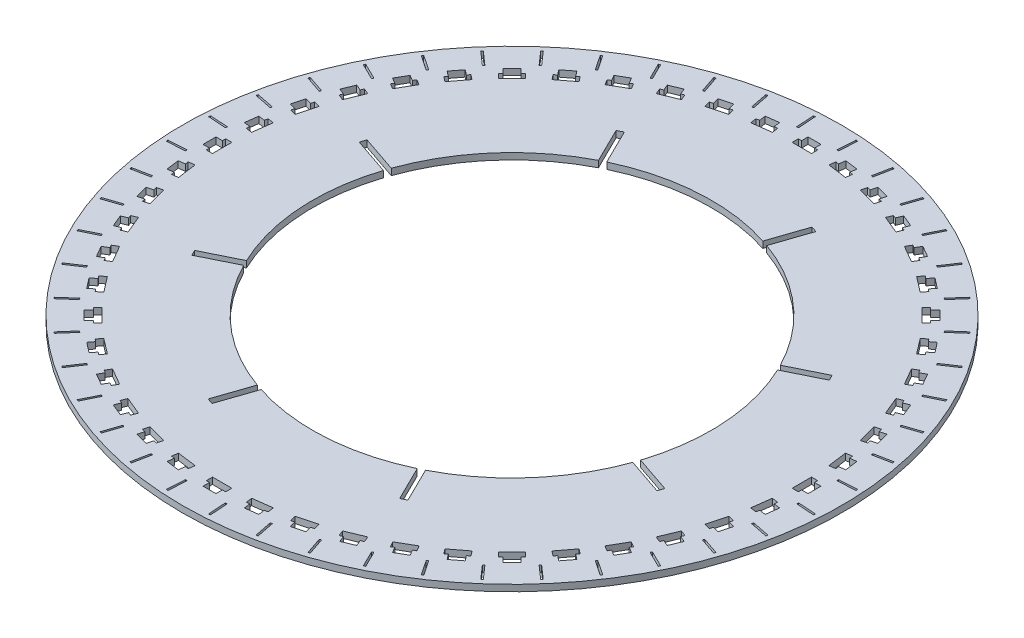
from build123d import *

# Parameters (mm, degrees)
SKETCH_1_R               = 254.62
SKETCH_1_R_2             = 154.62
EXTRUDE_1_DEPTH          = 5
SKETCH_2_W               = 10
SKETCH_2_H               = 5
CUT_EXTRUDE_1_DEPTH      = 6
PATTERN_CIRCULAR_1_COUNT = 48
CUT_EXTRUDE_2_DEPTH      = 5
PATTERN_CIRCULAR_2_COUNT = 48
SKETCH_4_R               = 255.62
SKETCH_4_R_2             = 254.62
EXTRUDE_2_DEPTH          = 5
CUT_EXTRUDE_3_DEPTH      = 5
PATTERN_CIRCULAR_3_COUNT = 8


with BuildPart() as part:
    # 草图1 → 凸台-拉伸1 (new body)
    with BuildSketch(Plane(origin=(0, 0, 0), x_dir=(1, 0, 0), z_dir=(0, 1, 0))):
        Circle(SKETCH_1_R)
        Circle(SKETCH_1_R_2, mode=Mode.SUBTRACT)
    extrude(amount=EXTRUDE_1_DEPTH)

    # 草图2 → 切除-拉伸1 (cut, through all)
    with BuildSketch(Plane(origin=(0, 5, 0), x_dir=(1, 0, 0), z_dir=(0, 1, 0))):
        Polygon((-7.5, -229.62), (-5, -229.62), (5, -229.62), (7.5, -229.62), (7.5, -224.82), (-7.5, -224.82), align=None)
        with Locations((0, -232.12)):
            Rectangle(SKETCH_2_W, SKETCH_2_H)
    cut_extrude_1 = extrude(amount=-CUT_EXTRUDE_1_DEPTH, mode=Mode.SUBTRACT)

    # 阵列(圆周)1: 切除-拉伸1 ×48 about axis
    pattern_circular_1_axis = Axis((0, 0, 0), (0, 1, 0))
    for i in range(1, PATTERN_CIRCULAR_1_COUNT):
        add(cut_extrude_1.rotate(pattern_circular_1_axis, i * 360 / PATTERN_CIRCULAR_1_COUNT), mode=Mode.SUBTRACT)

    # 草图3 → 切除-拉伸2 (cut)
    with BuildSketch(Plane(origin=(0, 5, 0), x_dir=(1, 0, 0), z_dir=(0, 1, 0))):
        Polygon((15.758234131, -251.127044456), (14.842590321, -237.15701953), (16.239592814, -237.065455149), (17.155236623, -251.035480075), align=None)
    cut_extrude_2 = extrude(amount=-CUT_EXTRUDE_2_DEPTH, mode=Mode.SUBTRACT)

    # 阵列(圆周)2: 切除-拉伸2 ×48 about axis
    pattern_circular_2_axis = Axis((0, 0, 0), (0, 1, 0))
    for i in range(1, PATTERN_CIRCULAR_2_COUNT):
        add(cut_extrude_2.rotate(pattern_circular_2_axis, i * 360 / PATTERN_CIRCULAR_2_COUNT), mode=Mode.SUBTRACT)

    # 草图4 → 凸台-拉伸2 (add)
    with BuildSketch(Plane(origin=(0, 5, 0), x_dir=(1, 0, 0), z_dir=(0, 1, 0))):
        Circle(SKETCH_4_R)
        Circle(SKETCH_4_R_2, mode=Mode.SUBTRACT)
    extrude(amount=-EXTRUDE_2_DEPTH)

    # 草图6 → 切除-拉伸3 (cut)
    with BuildSketch(Plane(origin=(0, 5, 0), x_dir=(1, 0, 0), z_dir=(0, 1, 0))):
        Polygon((112.829773906, 52.965521995), (166.642138398, 79.502843409), (164.519152685, 83.807832568), (110.706788193, 57.270511155), align=None)
    cut_extrude_3 = extrude(amount=-CUT_EXTRUDE_3_DEPTH, mode=Mode.SUBTRACT)

    # 阵列(圆周)3: 切除-拉伸3 ×8 about axis
    pattern_circular_3_axis = Axis((0, 0, 0), (0, 1, 0))
    for i in range(1, PATTERN_CIRCULAR_3_COUNT):
        add(cut_extrude_3.rotate(pattern_circular_3_axis, i * 360 / PATTERN_CIRCULAR_3_COUNT), mode=Mode.SUBTRACT)


solid = part.part
